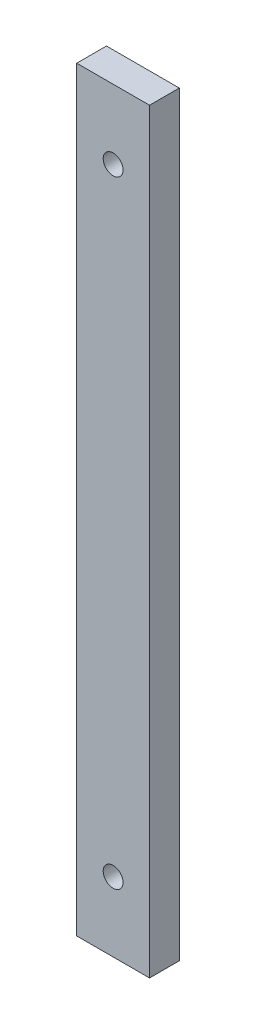
from build123d import *

# Parameters (mm, degrees)
SKETCH1_W           = 14.68
SKETCH1_H           = 152.4
BOSS_EXTRUDE1_DEPTH = 6
SKETCH2_R           = 2
CUT_EXTRUDE1_DEPTH  = 6


with BuildPart() as part:
    # Sketch1 → Boss-Extrude1 (new body)
    with BuildSketch(Plane.XY):
        Rectangle(SKETCH1_W, SKETCH1_H)
    extrude(amount=BOSS_EXTRUDE1_DEPTH)

    # Sketch2 → Cut-Extrude1 (cut)
    with BuildSketch(Plane.XY.offset(6)):
        with Locations((0, -62.2)):
            Circle(SKETCH2_R)
        with Locations((0, 62.2)):
            Circle(SKETCH2_R)
    extrude(amount=-CUT_EXTRUDE1_DEPTH, mode=Mode.SUBTRACT)


solid = part.part
